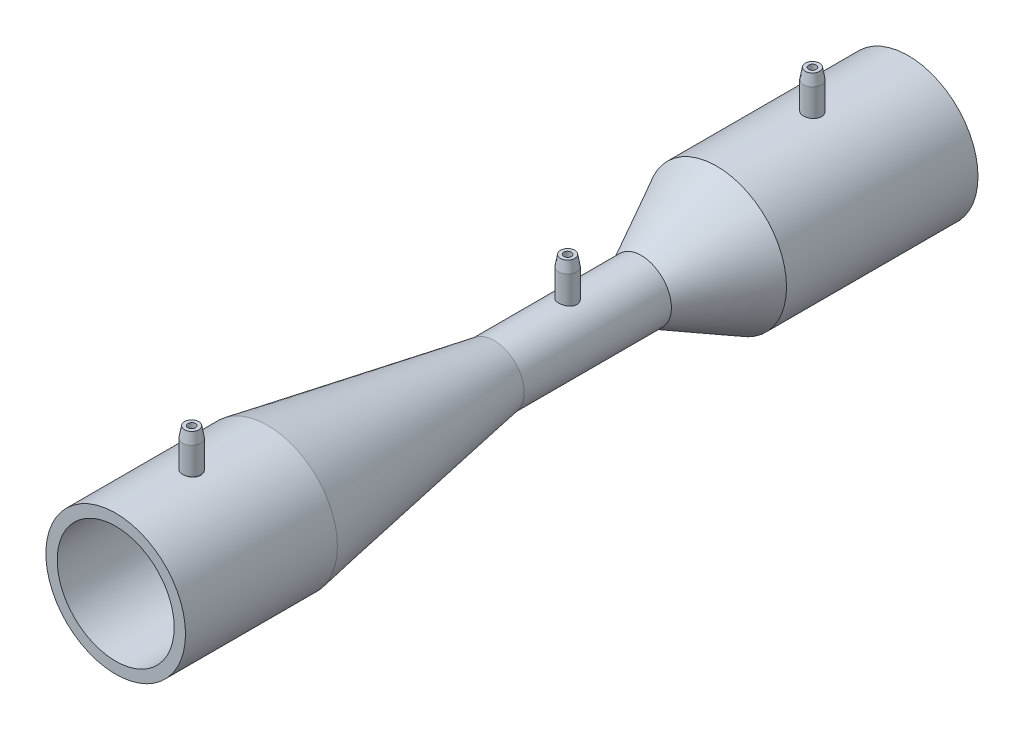
from build123d import *

# Parameters (mm, degrees)
SKETCH2_5_W        = 1.385
SKETCH2_5_H        = 13
SKETCH2_6_W        = 1.385
SKETCH2_6_H        = 13
CHAMFER1_SIZE      = 0.5
CHAMFER1_SIZE2     = 2.83564091
CHAMFER2_SIZE      = 0.5
CHAMFER2_SIZE2     = 2.83564091
CHAMFER3_SIZE      = 0.5
CHAMFER3_SIZE2     = 2.83564091
CUT_EXTRUDE2_START = -15
SKETCH4_R          = 1
CUT_EXTRUDE2_DEPTH = 15
CUT_EXTRUDE3_START = -15
SKETCH5_R          = 1
CUT_EXTRUDE3_DEPTH = 15
SKETCH6_R          = 1
CUT_EXTRUDE4_DEPTH = 30


with BuildPart() as part:
    # Sketch1 → Revolve1 (revolve)
    with BuildSketch(Plane(origin=(0, 0, 0), x_dir=(0, 0, -1), z_dir=(1, 0, 0))):
        Polygon((-135.628629381, 15.5), (-95.628629381, 15.5), (-35.628629381, 5), (4.371370619, 5), (24.371370619, 15.5), (74.371370619, 15.5), (74.371370619, 18.5), (23.631738049, 18.5), (3.631738049, 8), (-35.368108949, 8), (-95.368108949, 18.5), (-135.628629381, 18.5), align=None)
    revolve(axis=Axis((0, 0, -77.872340426), (0, 0, 1)))

    # Sketch2_5 → Revolve3 (revolve)
    with BuildSketch(Plane(origin=(0, 0, 0), x_dir=(0, 0, -1), z_dir=(1, 0, 0))):
        with Locations((-14.17568545, 11.5)):
            Rectangle(SKETCH2_5_W, SKETCH2_5_H)
    revolve(axis=Axis((0, 8, 15.86818545), (0, 1, 0)))

    # Sketch2_6 → Revolve4 (revolve)
    with BuildSketch(Plane(origin=(0, 0, 0), x_dir=(0, 0, -1), z_dir=(1, 0, 0))):
        with Locations((50.694054334, 22)):
            Rectangle(SKETCH2_6_W, SKETCH2_6_H)
    revolve(axis=Axis((0, 18.5, -49.001554334), (0, 1, 0)))

    # Chamfer2
    chamfer2_edges = [part.edges().sort_by_distance(p)[0] for p in [
        (0, 18, 18.25318545),
    ]]
    chamfer2_side = [part.faces().sort_by_distance(p)[0] for p in [
        (0, 18, 18.185727463),
    ]]
    chamfer(chamfer2_edges, length=CHAMFER2_SIZE, length2=CHAMFER2_SIZE2, reference=chamfer2_side[0])

    # Chamfer3
    chamfer3_edges = [part.edges().sort_by_distance(p)[0] for p in [
        (0, 28.5, -46.616554334),
    ]]
    chamfer3_side = [part.faces().sort_by_distance(p)[0] for p in [
        (0, 28.5, -46.684012321),
    ]]
    chamfer(chamfer3_edges, length=CHAMFER3_SIZE, length2=CHAMFER3_SIZE2, reference=chamfer3_side[0])

    # Sketch4 → Cut-Extrude2 (cut)
    with BuildSketch(Plane(origin=(0, 18, 0), x_dir=(1, 0, 0), z_dir=(0, 1, 0)).offset(CUT_EXTRUDE2_START)):
        with Locations((0, -15.86818545)):
            Circle(SKETCH4_R)
    extrude(amount=CUT_EXTRUDE2_DEPTH, mode=Mode.SUBTRACT)

    # Sketch5 → Cut-Extrude3 (cut)
    with BuildSketch(Plane(origin=(0, 28.5, 0), x_dir=(1, 0, 0), z_dir=(0, 1, 0)).offset(CUT_EXTRUDE3_START)):
        with Locations((0, 49.001554334)):
            Circle(SKETCH5_R)
    extrude(amount=CUT_EXTRUDE3_DEPTH, mode=Mode.SUBTRACT)

    # Sketch6 → Cut-Extrude4 (cut)
    with BuildSketch(Plane(origin=(0, 28.5, 0), x_dir=(1, 0, 0), z_dir=(0, 1, 0))):
        with Locations((0, -115.498369165)):
            Circle(SKETCH6_R)
    extrude(amount=-CUT_EXTRUDE4_DEPTH, mode=Mode.SUBTRACT)


with BuildPart() as body_2:
    # Sketch2 → Revolve2 (revolve)
    with BuildSketch(Plane(origin=(0, 0, 0), x_dir=(0, 0, -1), z_dir=(1, 0, 0))):
        Polygon((-113.108369165, 28.5), (-114.498369165, 28.5), (-114.498369165, 18.5), (-114.498369165, 15.5), (-113.113369165, 15.5), (-113.108369165, 18.5), align=None)
    revolve(axis=Axis((0, 18.5, 115.498369165), (0, 1, 0)))

    # Chamfer1
    chamfer1_edges = [body_2.edges().sort_by_distance(p)[0] for p in [
        (0, 28.5, 117.888369165),
    ]]
    chamfer1_side = [body_2.faces().sort_by_distance(p)[0] for p in [
        (0, 28.5, 117.820769756),
    ]]
    chamfer(chamfer1_edges, length=CHAMFER1_SIZE, length2=CHAMFER1_SIZE2, reference=chamfer1_side[0])


solid = Compound([part.part, body_2.part])
